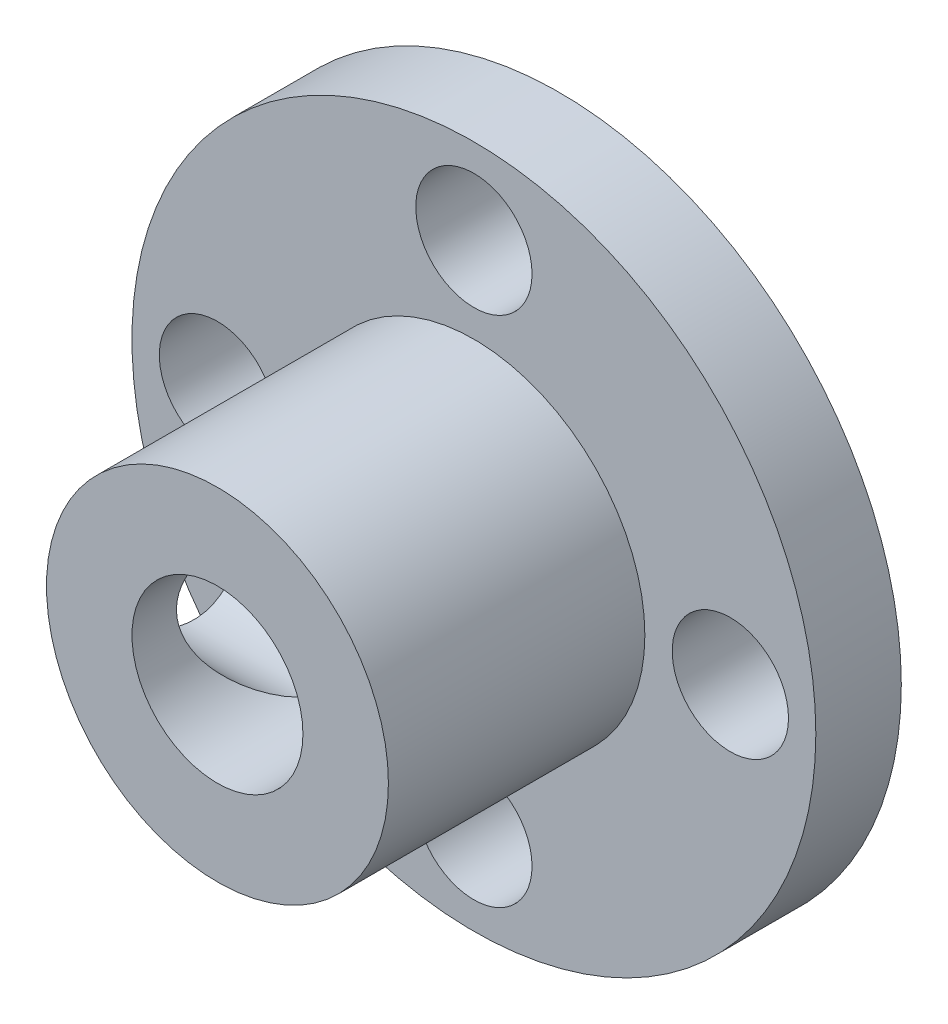
from build123d import *

# Parameters (mm, degrees)
SKETCH2_R           = 12.7
SKETCH2_R_2         = 6.35
SKETCH2_R_3         = 2.159
BOSS_EXTRUDE1_DEPTH = 3.175
SKETCH2_3_R         = 6.35
SKETCH2_3_R_2       = 3.175
BOSS_EXTRUDE2_DEPTH = 12.7
SKETCH4_R           = 3.048
CUT_EXTRUDE1_DEPTH  = 12.7


with BuildPart() as part:
    # Sketch2 → Boss-Extrude1 (new body)
    with BuildSketch(Plane.XY):
        Circle(SKETCH2_R)
        Circle(SKETCH2_R_2, mode=Mode.SUBTRACT)
        with Locations((0, 9.525)):
            Circle(SKETCH2_R_3, mode=Mode.SUBTRACT)
        with Locations((9.525, 0)):
            Circle(SKETCH2_R_3, mode=Mode.SUBTRACT)
        with Locations((0, -9.525)):
            Circle(SKETCH2_R_3, mode=Mode.SUBTRACT)
        with Locations((-9.525, 0)):
            Circle(SKETCH2_R_3, mode=Mode.SUBTRACT)
    extrude(amount=BOSS_EXTRUDE1_DEPTH)

    # Sketch2_3 → Boss-Extrude2 (add)
    with BuildSketch(Plane.XY):
        Circle(SKETCH2_3_R)
        Circle(SKETCH2_3_R_2, mode=Mode.SUBTRACT)
    extrude(amount=BOSS_EXTRUDE2_DEPTH)

    # Sketch4 → Cut-Extrude1 (cut)
    with BuildSketch(Plane(origin=(0, 0, 0), x_dir=(0, 0, -1), z_dir=(1, 0, 0))):
        with Locations((-8.001, 0)):
            Circle(SKETCH4_R)
    extrude(amount=-CUT_EXTRUDE1_DEPTH, mode=Mode.SUBTRACT)


solid = part.part
